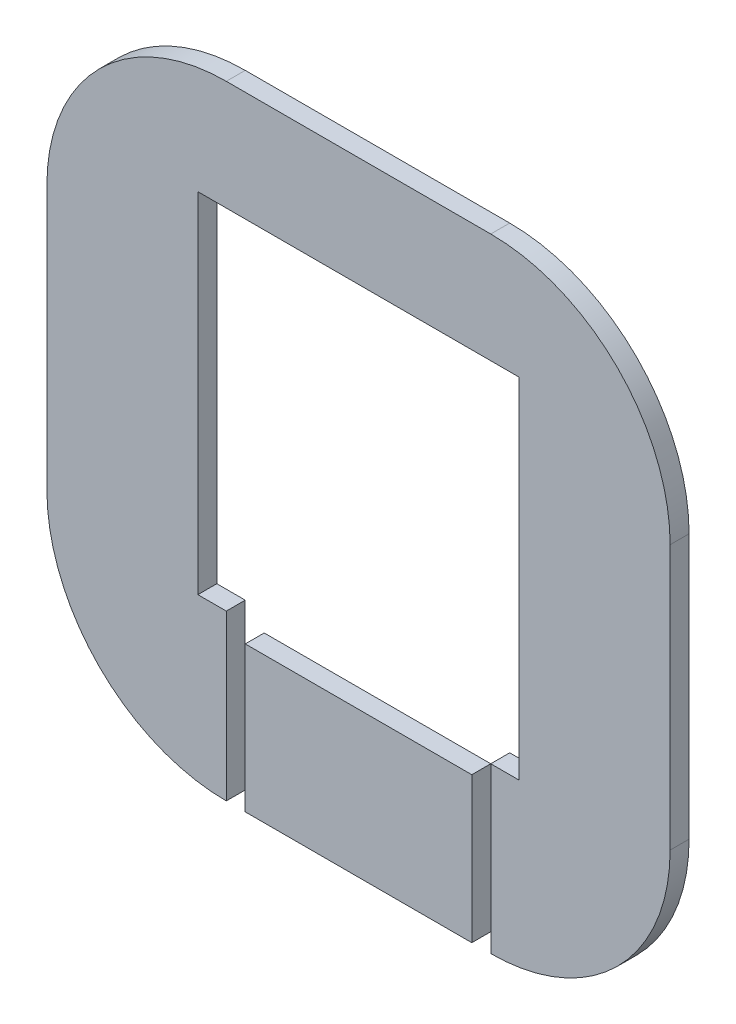
from build123d import *

# Parameters (mm, degrees)
BOSS_EXTRUDE1_DEPTH = 4.3
SKETCH2_W           = 4.3
SKETCH2_H           = 33.01
CUT_EXTRUDE1_DEPTH  = 4.3


with BuildPart() as part:
    # Sketch1 → Boss-Extrude1 (new body)
    with BuildSketch(Plane.XY):
        with BuildLine():
            Line((-0.5, -92.2), (0.5, -92.2))
            Line((0.5, -92.2), (30, -92.2))
            ThreePointArc((30, -92.2), (58.779245994, -80.279245994), (70.7, -51.5))
            Line((70.7, -51.5), (70.7, 8.5))
            ThreePointArc((70.7, 8.5), (58.779245994, 37.279245994), (30, 49.2))
            Line((30, 49.2), (-30, 49.2))
            ThreePointArc((-30, 49.2), (-58.779245994, 37.279245994), (-70.7, 8.5))
            Line((-70.7, 8.5), (-70.7, -51.5))
            ThreePointArc((-70.7, -51.5), (-58.779245994, -80.279245994), (-30, -92.2))
            Line((-30, -92.2), (-0.5, -92.2))
        make_face()
    extrude(amount=BOSS_EXTRUDE1_DEPTH)

    # Sketch2 → Cut-Extrude1 (cut)
    with BuildSketch(Plane.XY.offset(4.3)):
        Polygon((-36.45, -54.89), (-30, -54.89), (30, -54.89), (36.45, -54.89), (36.45, 24.29), (-36.45, 24.29), align=None)
        Polygon((-30, -54.89), (-30, -59.19), (-25.7, -59.19), (25.7, -59.19), (30, -59.19), (30, -54.89), align=None)
        with Locations((-27.85, -75.695)):
            Rectangle(SKETCH2_W, SKETCH2_H)
        with Locations((27.85, -75.695)):
            Rectangle(SKETCH2_W, SKETCH2_H)
    extrude(amount=-CUT_EXTRUDE1_DEPTH, mode=Mode.SUBTRACT)


solid = part.part
